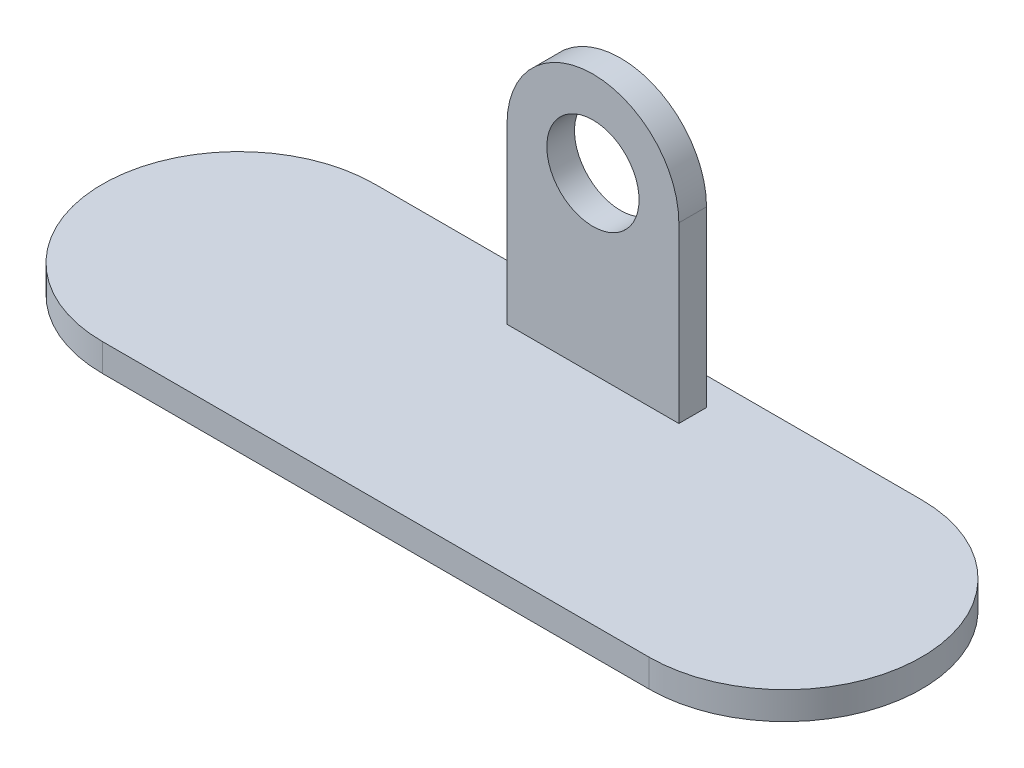
from build123d import *

# Parameters (mm, degrees)
SKETCH1_W           = 55.88
SKETCH1_H           = 9
BOSS_EXTRUDE1_DEPTH = 9
SKETCH2_R           = 15
BOSS_EXTRUDE2_DEPTH = 9


with BuildPart() as part:
    # Sketch1 → Boss-Extrude1 (new body)
    with BuildSketch(Plane(origin=(0, 0, 0), x_dir=(1, 0, 0), z_dir=(0, 1, 0))):
        with BuildLine():
            Line((-88.9, -44.323), (88.9, -44.323))
            ThreePointArc((88.9, -44.323), (133.223, 0), (88.9, 44.323))
            Line((88.9, 44.323), (-88.9, 44.323))
            ThreePointArc((-88.9, 44.323), (-133.223, 0), (-88.9, -44.323))
        make_face()
        with Locations((0, 30.823)):
            Rectangle(SKETCH1_W, SKETCH1_H, mode=Mode.SUBTRACT)
    extrude(amount=BOSS_EXTRUDE1_DEPTH)

    # Sketch2 → Boss-Extrude2 (add)
    with BuildSketch(Plane.XY.offset(-35.323)):
        with BuildLine():
            Line((-27.94, 0), (27.94, 0))
            Line((27.94, 0), (27.94, 65.532))
            ThreePointArc((27.94, 65.532), (0, 93.472), (-27.94, 65.532))
            Line((-27.94, 65.532), (-27.94, 0))
        make_face()
        with Locations((0, 65.532)):
            Circle(SKETCH2_R, mode=Mode.SUBTRACT)
    extrude(amount=BOSS_EXTRUDE2_DEPTH)


solid = part.part
